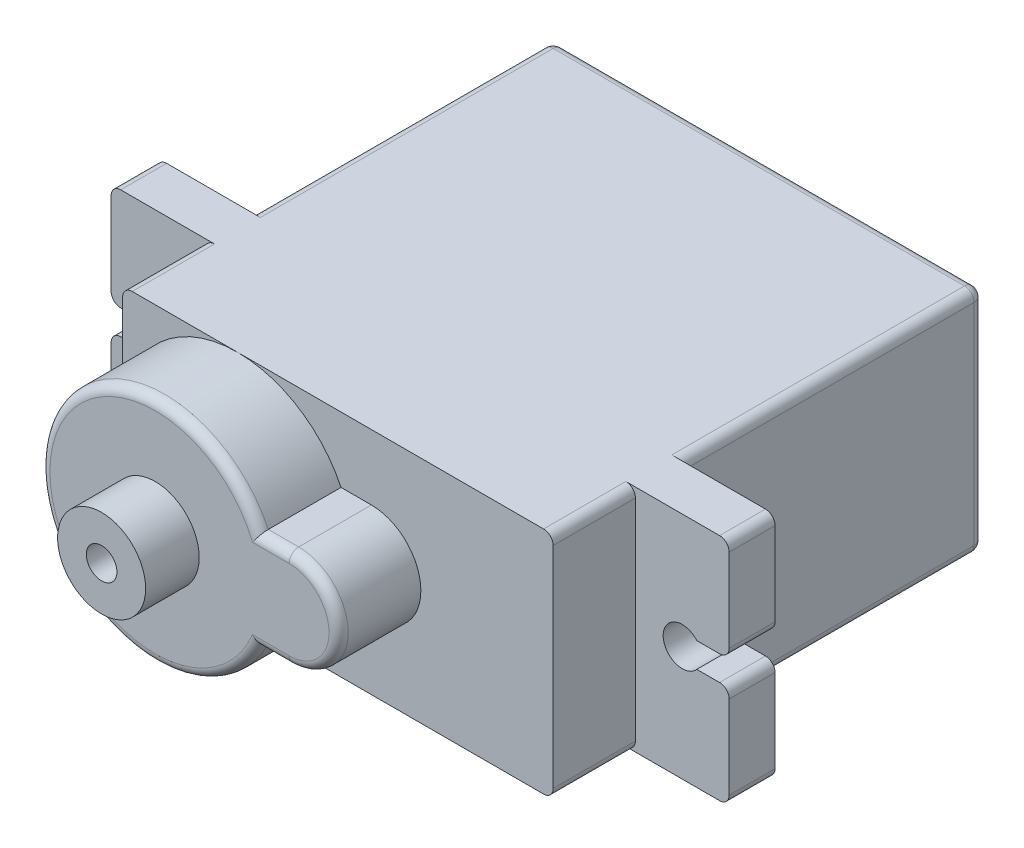
from build123d import *

# Parameters (mm, degrees)
SKETCH2_W                = 22.5
SKETCH2_H                = 12
BOSS_EXTRUDE1_DEPTH      = 22.5
SKETCH3_W                = 2.4
SKETCH3_H                = 12
BOSS_EXTRUDE2_DEPTH      = 4.9
BOSS_EXTRUDE2_DEPTH_BACK = 27.4
CUT_EXTRUDE1_REACH       = 20.2
SKETCH4_R                = 1
SKETCH5_R                = 6
BOSS_EXTRUDE3_DEPTH      = 4.3
SKETCH6_R                = 2.3
BOSS_EXTRUDE4_DEPTH      = 2.8
SKETCH7_R                = 0.8
CUT_EXTRUDE2_DEPTH       = 7
CUT_EXTRUDE3_REACH       = 20.2
SKETCH8_W                = 4.668208072
SKETCH8_H                = 1.3
SKETCH8_W_2              = 4.280898206
BOSS_EXTRUDE6_DEPTH      = 4.3
FILLET1_R                = 0.5


with BuildPart() as part:
    # Sketch2 → Boss-Extrude1 (new body)
    with BuildSketch(Plane.XY):
        with Locations((-4.403809909, 3.974212835)):
            Rectangle(SKETCH2_W, SKETCH2_H)
    extrude(amount=BOSS_EXTRUDE1_DEPTH)

    # Sketch3 → Boss-Extrude2 (add, two sides)
    with BuildSketch(Plane(origin=(6.846190091, 0, 0), x_dir=(0, 0, -1), z_dir=(1, 0, 0))) as boss_extrude2_sk:
        with Locations((-17, 3.974212835)):
            Rectangle(SKETCH3_W, SKETCH3_H)
    extrude(amount=BOSS_EXTRUDE2_DEPTH)
    extrude(boss_extrude2_sk.sketch, amount=-BOSS_EXTRUDE2_DEPTH_BACK)

    # Sketch4 → Cut-Extrude1 (cut, up to next)
    with BuildSketch(Plane.XY.offset(18.2), mode=Mode.PRIVATE) as cut_extrude1_sk1:
        with Locations((9.296190091, 3.974212835)):
            Circle(SKETCH4_R)
    cut_extrude1_tool1 = extrude(cut_extrude1_sk1.sketch, amount=-CUT_EXTRUDE1_REACH, mode=Mode.PRIVATE) & part.part
    add(cut_extrude1_tool1.solids().sort_by_distance((9.29619, 3.974213, 18.2))[0], mode=Mode.SUBTRACT)
    # Sketch4 → Cut-Extrude1 (cut, up to next)
    with BuildSketch(Plane.XY.offset(18.2), mode=Mode.PRIVATE) as cut_extrude1_sk2:
        with Locations((-18.103809909, 3.974212835)):
            Circle(SKETCH4_R)
    cut_extrude1_tool2 = extrude(cut_extrude1_sk2.sketch, amount=-CUT_EXTRUDE1_REACH, mode=Mode.PRIVATE) & part.part
    add(cut_extrude1_tool2.solids().sort_by_distance((-18.10381, 3.974213, 18.2))[0], mode=Mode.SUBTRACT)

    # Sketch5 → Boss-Extrude3 (add)
    with BuildSketch(Plane.XY.offset(22.5)):
        with Locations((-9.653809909, 3.974212835)):
            Circle(SKETCH5_R)
    extrude(amount=BOSS_EXTRUDE3_DEPTH)

    # Sketch6 → Boss-Extrude4 (add)
    with BuildSketch(Plane.XY.offset(26.8)):
        with Locations((-9.653809909, 3.974212835)):
            Circle(SKETCH6_R)
    extrude(amount=BOSS_EXTRUDE4_DEPTH)

    # Sketch7 → Cut-Extrude2 (cut)
    with BuildSketch(Plane.XY.offset(29.6)):
        with Locations((-9.653809909, 3.974212835)):
            Circle(SKETCH7_R)
    extrude(amount=-CUT_EXTRUDE2_DEPTH, mode=Mode.SUBTRACT)

    # Sketch8 → Cut-Extrude3 (cut, up to next)
    with BuildSketch(Plane.XY.offset(18.2), mode=Mode.PRIVATE) as cut_extrude3_sk1:
        with Locations((-20.553809909, 3.974212835)):
            Rectangle(SKETCH8_W, SKETCH8_H)
    cut_extrude3_tool1 = extrude(cut_extrude3_sk1.sketch, amount=-CUT_EXTRUDE3_REACH, mode=Mode.PRIVATE) & part.part
    add(cut_extrude3_tool1.solids().sort_by_distance((-20.55381, 3.974213, 18.2))[0], mode=Mode.SUBTRACT)
    # Sketch8 → Cut-Extrude3 (cut, up to next)
    with BuildSketch(Plane.XY.offset(18.2), mode=Mode.PRIVATE) as cut_extrude3_sk2:
        with Locations((11.746190091, 3.974212835)):
            Rectangle(SKETCH8_W_2, SKETCH8_H)
    cut_extrude3_tool2 = extrude(cut_extrude3_sk2.sketch, amount=-CUT_EXTRUDE3_REACH, mode=Mode.PRIVATE) & part.part
    add(cut_extrude3_tool2.solids().sort_by_distance((11.74619, 3.974213, 18.2))[0], mode=Mode.SUBTRACT)

    # Sketch9 → Boss-Extrude6 (add)
    with BuildSketch(Plane.XY.offset(22.5)):
        with BuildLine():
            Line((-2.653809909, 6.560409726), (-4.239792395, 6.560409726))
            Line((-4.239792395, 6.560409726), (-4.239792395, 1.388015944))
            Line((-4.239792395, 1.388015944), (-2.653809909, 1.388015944))
            ThreePointArc((-2.653809909, 1.388015944), (-0.067613018, 3.974212835), (-2.653809909, 6.560409726))
        make_face()
    extrude(amount=BOSS_EXTRUDE6_DEPTH)

    # Fillet1
    fillet1_edges = [part.edges().sort_by_distance(p)[0] for p in [
        (-15.653809909, 9.974212835, 7.9),
        (6.846190091, 9.974212835, 7.9),
        (6.846190091, -2.025787165, 7.9),
        (-15.653809909, -2.025787165, 7.9),
        (-20.553809909, 9.974212835, 17),
        (-20.553809909, -2.025787165, 17),
        (11.746190091, -2.025787165, 17),
        (11.746190091, 9.974212835, 17),
        (-4.403809909, 9.974212835, 0),
        (6.846190091, 3.974212835, 0),
        (-15.653809909, 3.974212835, 26.8),
        (-4.403809909, -2.025787165, 0),
        (-15.653809909, 3.974212835, 0),
        (-20.553809909, 3.324212835, 17),
        (-20.553809909, 4.624212835, 17),
        (-15.653809909, 9.974212835, 20.35),
        (6.846190091, 9.974212835, 20.35),
        (6.846190091, -2.025787165, 20.35),
        (-15.653809909, -2.025787165, 20.35),
        (11.746190091, 3.324212835, 17),
        (11.746190091, 4.624212835, 17),
        (-3.446801152, 1.388015944, 26.8),
        (-0.067613018, 3.974212835, 26.8),
        (-3.446801152, 6.560409726, 26.8),
    ]]
    fillet(fillet1_edges, radius=FILLET1_R)


solid = part.part
